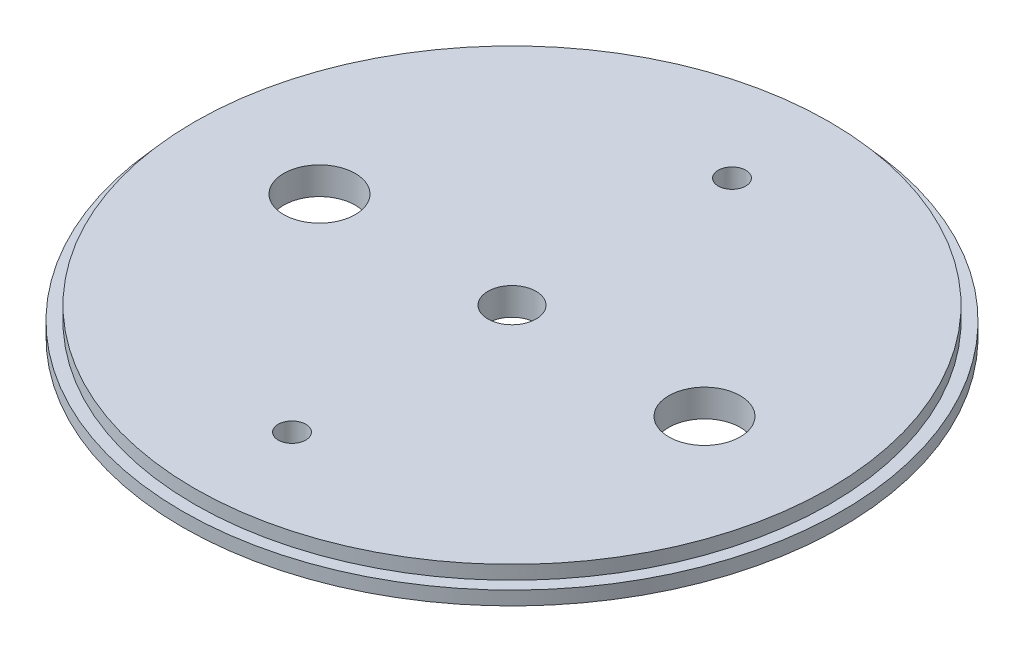
from build123d import *

# Parameters (mm, degrees)
SKETCH1_R                   = 76.0984
BOSS_EXTRUDE1_DEPTH         = 3.175
SKETCH1_3_R                 = 73.3171
BOSS_EXTRUDE2_DEPTH         = 6.35
F_1_4_0_25_DIAMETER_HOLE1_D = 6.35
M18X1_5_TAPPED_HOLE1_D      = 16.5
SKETCH3_3_R                 = 5.55625
CUT_EXTRUDE2_DEPTH          = 108.806565037


with BuildPart() as part:
    # Sketch1 → Boss-Extrude1 (new body)
    with BuildSketch(Plane(origin=(0, 0, 0), x_dir=(1, 0, 0), z_dir=(0, 1, 0))):
        Circle(SKETCH1_R)
    extrude(amount=BOSS_EXTRUDE1_DEPTH)

    # Sketch1_3 → Boss-Extrude2 (add)
    with BuildSketch(Plane(origin=(0, 0, 0), x_dir=(1, 0, 0), z_dir=(0, 1, 0))):
        Circle(SKETCH1_3_R)
    extrude(amount=BOSS_EXTRUDE2_DEPTH)

    # 1_4 _0.25_ Diameter Hole1 (through all)
    with Locations(Plane(origin=(0, 0, 0), x_dir=(-1, 0, 0), z_dir=(0, -1, 0))):
        with Locations((0, 50.8), (0, -50.8)):
            Hole(F_1_4_0_25_DIAMETER_HOLE1_D / 2)

    # M18x1.5 Tapped Hole1 (through all)
    with Locations(Plane(origin=(0, 0, 0), x_dir=(-1, 0, 0), z_dir=(0, -1, 0))):
        with Locations((44.45, 0), (-44.45, 0)):
            Hole(M18X1_5_TAPPED_HOLE1_D / 2)

    # Sketch3_3 → Cut-Extrude2 (cut, through all)
    with BuildSketch(Plane.XZ):
        Circle(SKETCH3_3_R)
    extrude(amount=-CUT_EXTRUDE2_DEPTH, mode=Mode.SUBTRACT)


solid = part.part
